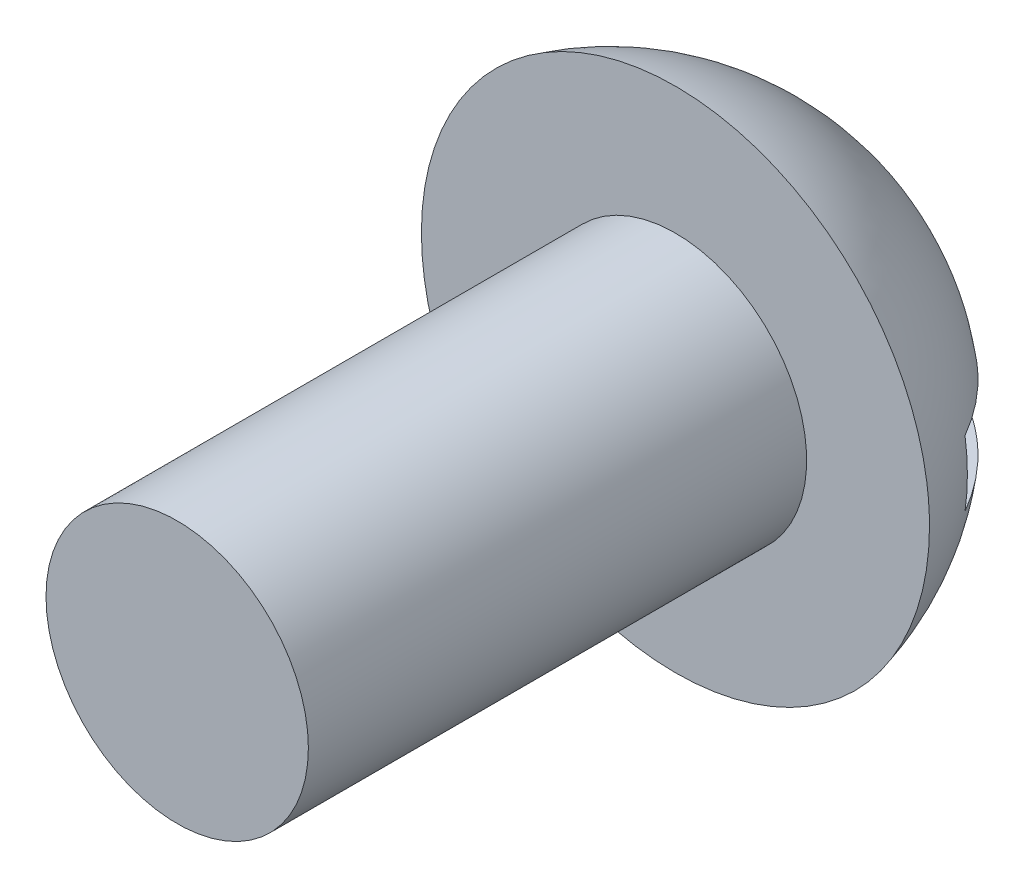
from build123d import *

# Parameters (mm, degrees)
SKETCH2_R           = 1.2573
BOSS_EXTRUDE1_DEPTH = 4.7752
CUT_EXTRUDE1_DEPTH  = 3.434750981


with BuildPart() as part:
    # Sketch1 → Base-Revolve (revolve)
    with BuildSketch(Plane(origin=(0, 0, 0), x_dir=(0, 0, -1), z_dir=(1, 0, 0))):
        with BuildLine():
            Line((-22.86, 15.282157927), (-20.97405, 15.282157927))
            ThreePointArc((-20.97405, 15.282157927), (-21.500684149, 16.822029654), (-22.86, 17.716908908))
            Line((-22.86, 17.716908908), (-22.86, 15.282157927))
        make_face()
    revolve(axis=Axis((0, 15.282157927, 28.59405), (0, 0, -1)))

    # Sketch2 → Boss-Extrude1 (add)
    with BuildSketch(Plane.XY.offset(22.86)):
        with Locations((0, 15.24)):
            Circle(SKETCH2_R)
    extrude(amount=BOSS_EXTRUDE1_DEPTH)

    # Sketch4 → Cut-Extrude1 (cut, through all)
    with BuildSketch(Plane(origin=(0, 0, 0), x_dir=(0, 0, -1), z_dir=(1, 0, 0))):
        with BuildLine():
            Line((-22.251072657, 14.967832927), (-20.993772657, 14.967832927))
            ThreePointArc((-20.993772657, 14.967832927), (-20.97405, 15.282157927), (-20.993772657, 15.596482927))
            Line((-20.993772657, 15.596482927), (-22.251072657, 15.596482927))
            Line((-22.251072657, 15.596482927), (-22.251072657, 14.967832927))
        make_face()
    cut_extrude1 = extrude(amount=-CUT_EXTRUDE1_DEPTH, mode=Mode.SUBTRACT)

    # Mirror1: Cut-Extrude1 across plane
    add(cut_extrude1.mirror(Plane(origin=(0, 15.282157927, 23.48865), x_dir=(0, 0, 1), z_dir=(1, 0, 0))), mode=Mode.SUBTRACT)


solid = part.part
